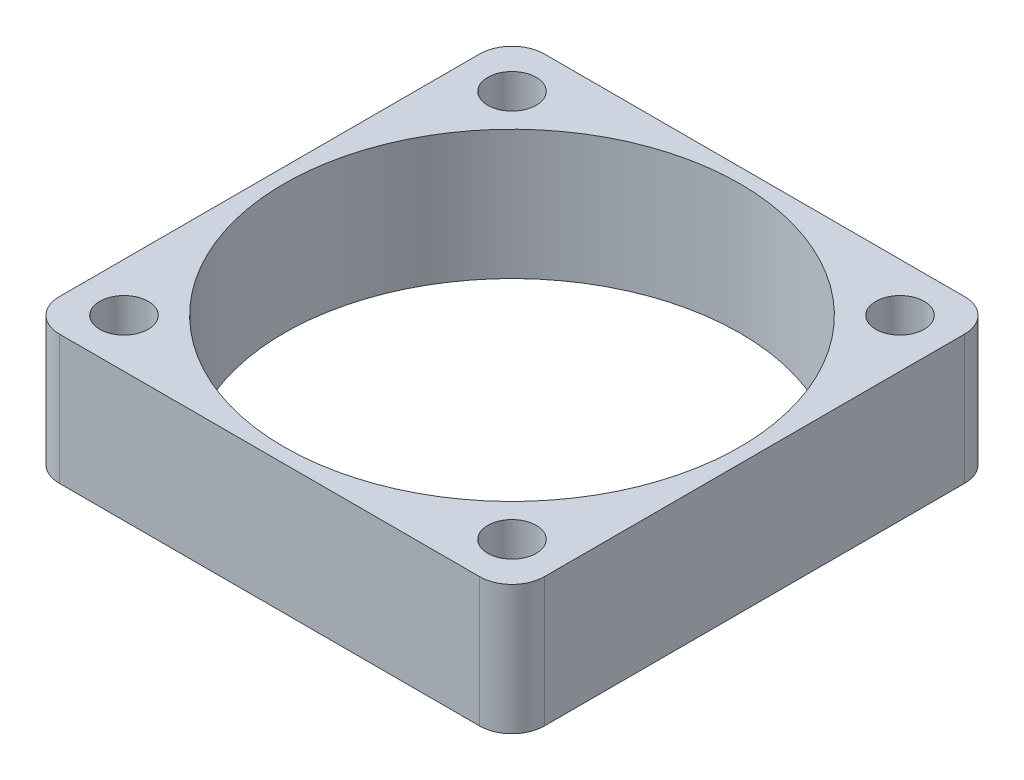
from build123d import *

# Parameters (mm, degrees)
SKETCH1_W           = 30
SKETCH1_H           = 30
BOSS_EXTRUDE1_DEPTH = 8
FILLET1_R           = 2
SKETCH2_R           = 1.5
CUT_EXTRUDE1_DEPTH  = 8
SKETCH3_R           = 14.1
CUT_EXTRUDE2_DEPTH  = 8


with BuildPart() as part:
    # Sketch1 → Boss-Extrude1 (new body)
    with BuildSketch(Plane(origin=(0, 0, 0), x_dir=(1, 0, 0), z_dir=(0, 1, 0))):
        Rectangle(SKETCH1_W, SKETCH1_H)
    extrude(amount=BOSS_EXTRUDE1_DEPTH)

    # Fillet1
    fillet1_edges = [part.edges().sort_by_distance(p)[0] for p in [
        (-15, 4, -15),
        (15, 4, -15),
        (15, 4, 15),
        (-15, 4, 15),
    ]]
    fillet(fillet1_edges, radius=FILLET1_R)

    # Sketch2 → Cut-Extrude1 (cut)
    with BuildSketch(Plane(origin=(0, 8, 0), x_dir=(1, 0, 0), z_dir=(0, 1, 0))):
        with Locations((-12, 12)):
            Circle(SKETCH2_R)
        with Locations((12, 12)):
            Circle(SKETCH2_R)
        with Locations((-12, -12)):
            Circle(SKETCH2_R)
        with Locations((12, -12)):
            Circle(SKETCH2_R)
    extrude(amount=-CUT_EXTRUDE1_DEPTH, mode=Mode.SUBTRACT)

    # Sketch3 → Cut-Extrude2 (cut)
    with BuildSketch(Plane(origin=(0, 8, 0), x_dir=(1, 0, 0), z_dir=(0, 1, 0))):
        Circle(SKETCH3_R)
    extrude(amount=-CUT_EXTRUDE2_DEPTH, mode=Mode.SUBTRACT)


solid = part.part
